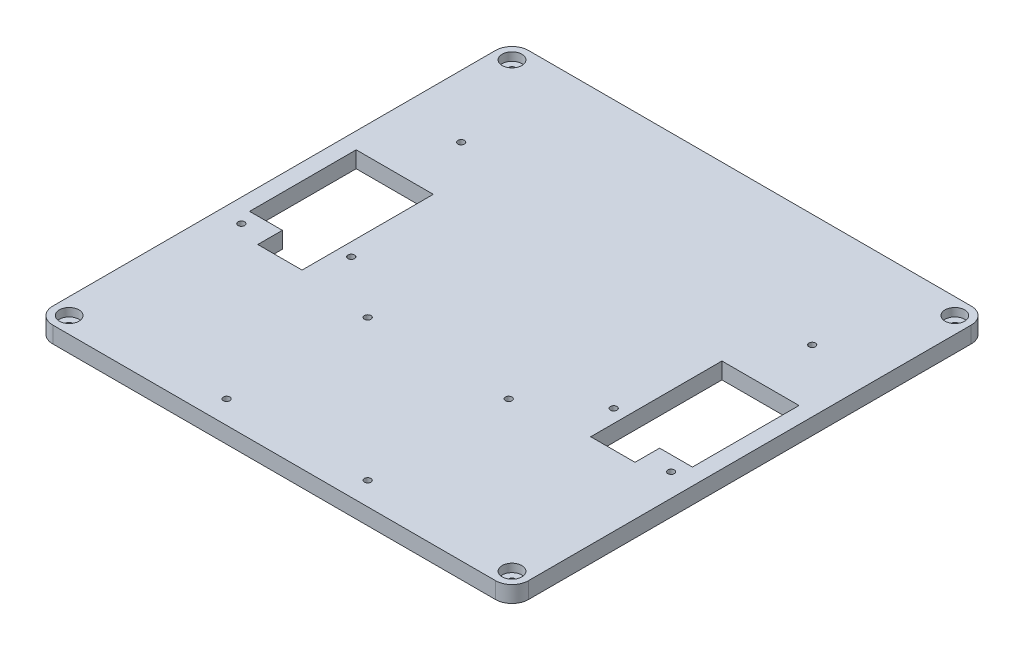
from build123d import *

# Parameters (mm, degrees)
ESQUISSE2_W             = 290
ESQUISSE2_H             = 290
ESQUISSE2_R             = 2
BOSS_EXTRU_1_DEPTH      = 10
ESQUISSE3_R             = 2
ENL_V_MAT_EXTRU_1_DEPTH = 10
CONG_1_R                = 10
ESQUISSE4_R             = 6
ENL_V_MAT_EXTRU_2_DEPTH = 5
ESQUISSE5_R             = 2
ENL_V_MAT_EXTRU_3_DEPTH = 10


with BuildPart() as part:
    # Esquisse2 → Boss.-Extru.1 (new body)
    with BuildSketch(Plane(origin=(0, 0, 0), x_dir=(1, 0, 0), z_dir=(0, 1, 0))):
        with Locations((145, 145)):
            Rectangle(ESQUISSE2_W, ESQUISSE2_H)
        with Locations((276, 111)):
            Circle(ESQUISSE2_R, mode=Mode.SUBTRACT)
        with Locations((225, 127)):
            Circle(ESQUISSE2_R, mode=Mode.SUBTRACT)
        with Locations((252, 221)):
            Circle(ESQUISSE2_R, mode=Mode.SUBTRACT)
        with Locations((14, 111)):
            Circle(ESQUISSE2_R, mode=Mode.SUBTRACT)
        with Locations((65, 127)):
            Circle(ESQUISSE2_R, mode=Mode.SUBTRACT)
        with Locations((38, 221)):
            Circle(ESQUISSE2_R, mode=Mode.SUBTRACT)
        Polygon((233, 185), (233, 145), (233, 105), (260, 105), (260, 120), (280, 120), (280, 185), align=None, mode=Mode.SUBTRACT)
        Polygon((30, 105), (30, 120), (10, 120), (10, 185), (57, 185), (57, 145), (57, 105), align=None, mode=Mode.SUBTRACT)
    extrude(amount=BOSS_EXTRU_1_DEPTH)

    # Esquisse3 → Enlèv. mat.-Extru.1 (cut)
    with BuildSketch(Plane(origin=(0, 10, 0), x_dir=(1, 0, 0), z_dir=(0, 1, 0))):
        with Locations((10, 280)):
            Circle(ESQUISSE3_R)
        with Locations((280, 280)):
            Circle(ESQUISSE3_R)
        with Locations((280, 10)):
            Circle(ESQUISSE3_R)
        with Locations((10, 10)):
            Circle(ESQUISSE3_R)
    extrude(amount=-ENL_V_MAT_EXTRU_1_DEPTH, mode=Mode.SUBTRACT)

    # Congé1
    cong_1_edges = [part.edges().sort_by_distance(p)[0] for p in [
        (0, 5, -290),
        (290, 5, -290),
        (290, 5, 0),
        (0, 5, 0),
    ]]
    fillet(cong_1_edges, radius=CONG_1_R)

    # Esquisse4 → Enlèv. mat.-Extru.2 (cut)
    with BuildSketch(Plane(origin=(0, 10, 0), x_dir=(1, 0, 0), z_dir=(0, 1, 0))):
        with Locations((10, 280)):
            Circle(ESQUISSE4_R)
        with Locations((280, 280)):
            Circle(ESQUISSE4_R)
        with Locations((280, 10)):
            Circle(ESQUISSE4_R)
        with Locations((10, 10)):
            Circle(ESQUISSE4_R)
    extrude(amount=-ENL_V_MAT_EXTRU_2_DEPTH, mode=Mode.SUBTRACT)

    # Esquisse5 → Enlèv. mat.-Extru.3 (cut)
    with BuildSketch(Plane.XZ):
        with Locations((102, -14)):
            Circle(ESQUISSE5_R)
        with Locations((188, -14)):
            Circle(ESQUISSE5_R)
        with Locations((188, -100)):
            Circle(ESQUISSE5_R)
        with Locations((102, -100)):
            Circle(ESQUISSE5_R)
    extrude(amount=-ENL_V_MAT_EXTRU_3_DEPTH, mode=Mode.SUBTRACT)


solid = part.part
